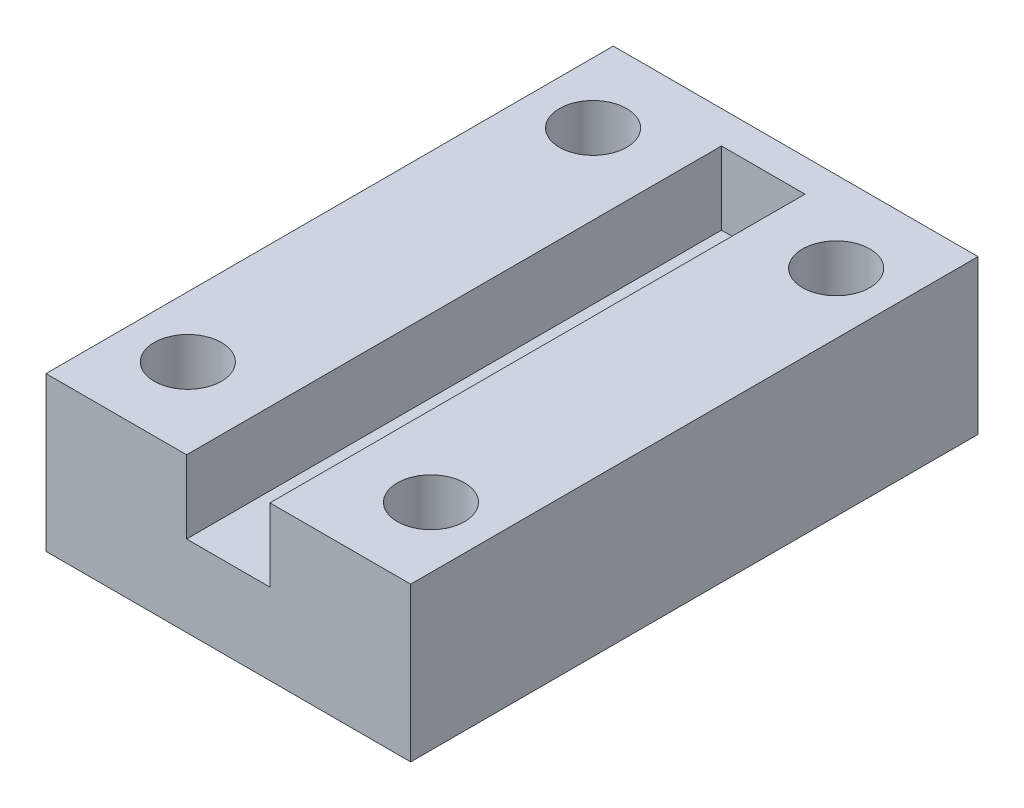
from build123d import *

# Parameters (mm, degrees)
SKETCH1_W           = 45
SKETCH1_H           = 70
BOSS_EXTRUDE1_DEPTH = 10
SKETCH3_R           = 4.15
CUT_EXTRUDE2_DEPTH  = 11
SKETCH5_R           = 4.15
BOSS_EXTRUDE2_DEPTH = 9
CHAMFER1_SIZE       = 1
CHAMFER1_SIZE2      = 1.191753593


with BuildPart() as part:
    # Sketch1 → Boss-Extrude1 (new body)
    with BuildSketch(Plane(origin=(0, 0, 0), x_dir=(1, 0, 0), z_dir=(0, 1, 0))):
        Rectangle(SKETCH1_W, SKETCH1_H)
    extrude(amount=BOSS_EXTRUDE1_DEPTH)

    # Sketch3 → Cut-Extrude2 (cut, through all)
    with BuildSketch(Plane.XZ):
        with Locations((15, 25)):
            Circle(SKETCH3_R)
        with Locations((15, -25)):
            Circle(SKETCH3_R)
        with Locations((-15, -25)):
            Circle(SKETCH3_R)
        with Locations((-15, 25)):
            Circle(SKETCH3_R)
    extrude(amount=-CUT_EXTRUDE2_DEPTH, mode=Mode.SUBTRACT)

    # Sketch5 → Boss-Extrude2 (add)
    with BuildSketch(Plane(origin=(0, 10, 0), x_dir=(1, 0, 0), z_dir=(0, 1, 0))):
        Polygon((-5.15, -35), (-22.5, -35), (-22.5, 35), (22.5, 35), (22.5, -35), (5.15, -35), (5.130229348, -34.949305848), (5.15, 31), (-5.15, 31), align=None)
        with Locations((-15, 25)):
            Circle(SKETCH5_R, mode=Mode.SUBTRACT)
        with Locations((15, 25)):
            Circle(SKETCH5_R, mode=Mode.SUBTRACT)
        with Locations((15, -25)):
            Circle(SKETCH5_R, mode=Mode.SUBTRACT)
        with Locations((-15, -25)):
            Circle(SKETCH5_R, mode=Mode.SUBTRACT)
    extrude(amount=BOSS_EXTRUDE2_DEPTH)

    # Chamfer1
    chamfer1_edges = [part.edges().sort_by_distance(p)[0] for p in [
        (-19.15, 0, -25),
        (-19.15, 0, 25),
        (10.85, 0, 25),
        (10.85, 0, -25),
    ]]
    chamfer1_side = [part.faces().sort_by_distance(p)[0] for p in [
        (0, 0, 0),
    ]]
    chamfer(chamfer1_edges, length=CHAMFER1_SIZE, length2=CHAMFER1_SIZE2, reference=chamfer1_side[0])


solid = part.part
